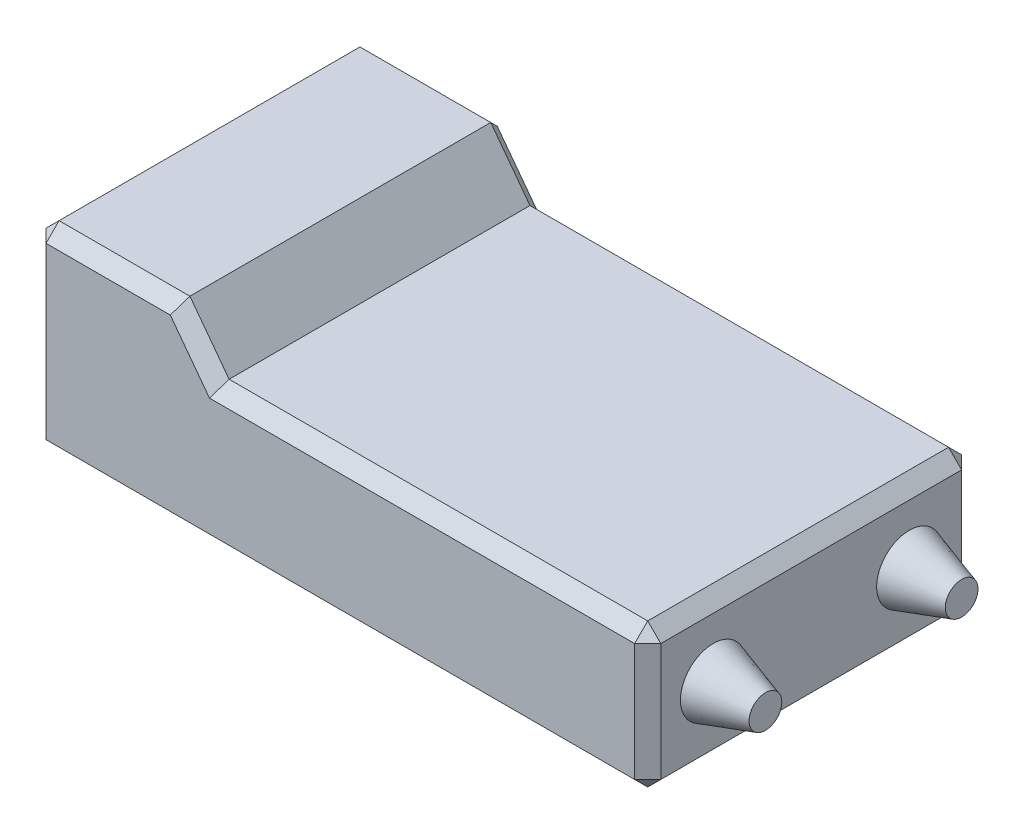
from build123d import *

# Parameters (mm, degrees)
SKETCH2_W            = 47
SKETCH2_H            = 25
BOSS_EXTRUDE1_DEPTH  = 11
BOSS_EXTRUDE2_DEPTH  = 25
SKETCH4_W            = 21
SKETCH4_H            = 11
CUT_EXTRUDE1_DEPTH   = 5
SKETCH5_R            = 2.5
SKETCH6_R            = 1.25
CHAMFER1_SIZE        = 1
SKETCH7_W            = 0.855148952
SKETCH7_H            = 0.908595762
BOSS_EXTRUDE3_DEPTH  = 5
LPATTERN1_COUNT      = 7
LPATTERN1_PITCH      = 2.833333333
LPATTERN1_COUNT_DIR2 = 3
LPATTERN1_PITCH_DIR2 = 3.5


with BuildPart() as part:
    # Sketch2 → Boss-Extrude1 (new body)
    with BuildSketch(Plane(origin=(0, 0, 0), x_dir=(1, 0, 0), z_dir=(0, 1, 0))):
        Rectangle(SKETCH2_W, SKETCH2_H)
    extrude(amount=BOSS_EXTRUDE1_DEPTH)

    # Sketch3 → Boss-Extrude2 (add)
    with BuildSketch(Plane.XY.offset(12.5)):
        Polygon((-23.5, 11), (-9.5, 11), (-12.5, 15), (-23.5, 15), align=None)
    extrude(amount=-BOSS_EXTRUDE2_DEPTH)

    # Sketch4 → Cut-Extrude1 (cut)
    with BuildSketch(Plane.ZY.offset(23.5)):
        with Locations((0, 7.5)):
            Rectangle(SKETCH4_W, SKETCH4_H)
    extrude(amount=-CUT_EXTRUDE1_DEPTH, mode=Mode.SUBTRACT)

    # Sketch5 → Loft1 section 0
    with BuildSketch(Plane(origin=(23.5, 0, 0), x_dir=(0, 0, -1), z_dir=(1, 0, 0))):
        with Locations((-7.5, 5.5)):
            Circle(SKETCH5_R)
    # Sketch6 → Loft1 section 1
    with BuildSketch(Plane(origin=(27.5, 0, 0), x_dir=(0, 0, -1), z_dir=(1, 0, 0))):
        with Locations((-7.5, 5.5)):
            Circle(SKETCH6_R)
    loft1 = loft()

    # Mirror1: Loft1 across plane
    add(loft1.mirror(Plane.XY))

    # Chamfer1
    chamfer1_edges = [part.edges().sort_by_distance(p)[0] for p in [
        (7, 11, 12.5),
        (-23.5, 15, 0),
        (-11, 13, 12.5),
        (-18, 15, 12.5),
        (-18, 15, -12.5),
        (-11, 13, -12.5),
        (23.5, 11, 0),
        (0, 0, 12.5),
        (-23.5, 0, 0),
        (0, 0, -12.5),
        (23.5, 0, 0),
        (23.5, 5.5, 12.5),
        (-23.5, 7.5, 12.5),
        (-23.5, 7.5, -12.5),
        (23.5, 5.5, -12.5),
        (7, 11, -12.5),
    ]]
    chamfer(chamfer1_edges, length=CHAMFER1_SIZE)

    # Sketch7 → Boss-Extrude3 (add)
    with BuildSketch(Plane.ZY.offset(18.5)):
        with Locations((-8.5, 4)):
            Rectangle(SKETCH7_W, SKETCH7_H)
    boss_extrude3 = extrude(amount=BOSS_EXTRUDE3_DEPTH)

    # LPattern1: Boss-Extrude3 7 × 3
    with Locations(*[(0, j * LPATTERN1_PITCH_DIR2, i * LPATTERN1_PITCH) for i in range(LPATTERN1_COUNT) for j in range(LPATTERN1_COUNT_DIR2) if (i, j) != (0, 0)]):
        add(boss_extrude3)


solid = part.part
